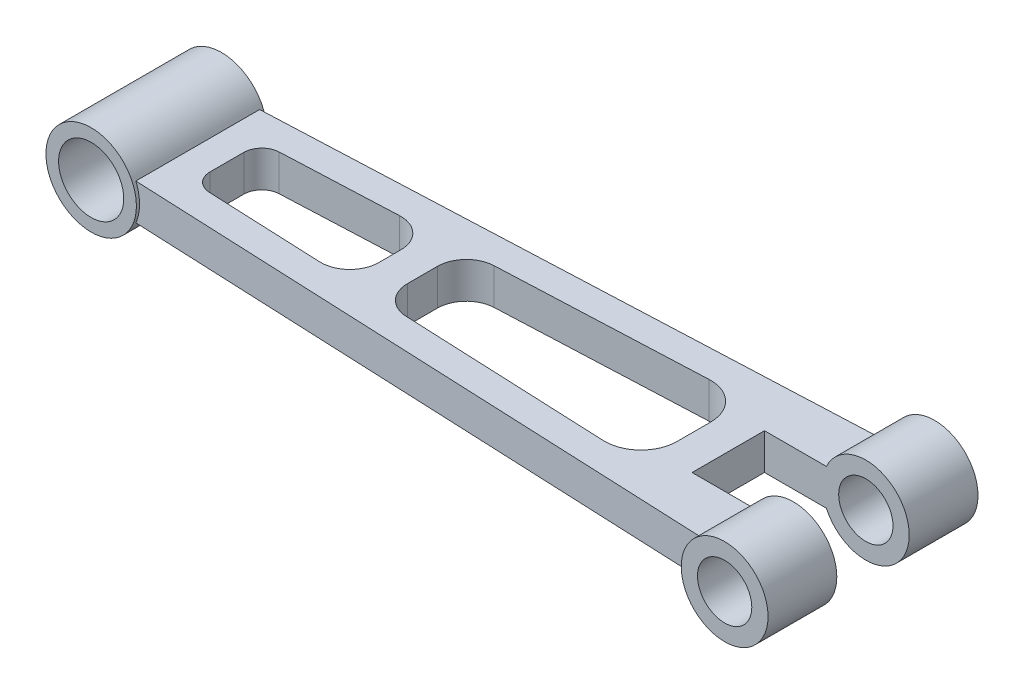
from build123d import *

# Parameters (mm, degrees)
BOSS_EXTRUDE1_DEPTH      = 10
SKETCH2_W                = 45.039354618
SKETCH2_H                = 20
CUT_EXTRUDE1_DEPTH       = 87.816421854
BOSS_EXTRUDE2_DEPTH      = 18
BOSS_EXTRUDE2_DEPTH_BACK = 18
SKETCH3_R                = 12.5
SKETCH4_R                = 9
CUT_EXTRUDE2_DEPTH       = 116.22555562
BOSS_EXTRUDE4_DEPTH      = 29
BOSS_EXTRUDE4_DEPTH_BACK = 29
SKETCH7_R                = 11.988578659
SKETCH8_R                = 7.5
CUT_EXTRUDE3_DEPTH       = 122.874166664
SKETCH2_2_W              = 45.039354618
SKETCH2_2_H              = 20
CUT_EXTRUDE4_DEPTH       = 112.041940275
CUT_EXTRUDE5_DEPTH       = 112.041940275
CUT_EXTRUDE5_DEPTH_BACK  = 112.041940275
SKETCH2_3_W              = 45.039354618
SKETCH2_3_H              = 20


with BuildPart() as part:
    # Sketch1 → Boss-Extrude1 (new body)
    with BuildSketch(Plane(origin=(0, 0, 0), x_dir=(1, 0, 0), z_dir=(0, 1, 0))):
        Polygon((-82.75, 0), (-82.75, 17.05432407), (82.75, 24.280210121), (82.75, 0), align=None)
    boss_extrude1 = extrude(amount=BOSS_EXTRUDE1_DEPTH)

    # Mirror1: Boss-Extrude1 across plane
    add(boss_extrude1.mirror(Plane.XY))

    # Sketch2 → Cut-Extrude1 (cut, through all)
    with BuildSketch(Plane(origin=(0, 10, 0), x_dir=(1, 0, 0), z_dir=(0, 1, 0))):
        with BuildLine():
            Line((-68.968096937, 9.648433472), (-37.098955099, 11.039870254))
            ThreePointArc((-37.098955099, 11.039870254), (-31.217895554, 8.826396178), (-28.75, 3.047484481))
            Line((-28.75, 3.047484481), (-28.75, -3.047484481))
            ThreePointArc((-28.75, -3.047484481), (-31.217895554, -8.826396178), (-37.098955099, -11.039870254))
            Line((-37.098955099, -11.039870254), (-68.968096937, -9.648433472))
            ThreePointArc((-68.968096937, -9.648433472), (-72.36181981, -8.110757643), (-73.75, -4.653192364))
            Line((-73.75, -4.653192364), (-73.75, 4.653192364))
            ThreePointArc((-73.75, 4.653192364), (-72.36181981, 8.110757643), (-68.968096937, 9.648433472))
        make_face()
        with BuildLine():
            Line((-19.75, 4.139008054), (-19.75, -4.139008054))
            ThreePointArc((-19.75, -4.139008054), (-17.528911696, -9.6711125), (-12.098955099, -12.131393827))
            Line((-12.098955099, -12.131393827), (44.813806126, -14.616258645))
            ThreePointArc((44.813806126, -14.616258645), (52.165130558, -11.84941605), (55.25, -4.625776429))
            Line((55.25, -4.625776429), (55.25, 4.625776429))
            ThreePointArc((55.25, 4.625776429), (52.165130558, 11.84941605), (44.813806126, 14.616258645))
            Line((44.813806126, 14.616258645), (-12.098955099, 12.131393827))
            ThreePointArc((-12.098955099, 12.131393827), (-17.528911696, 9.6711125), (-19.75, 4.139008054))
        make_face()
        with Locations((87.269677309, 0)):
            Rectangle(SKETCH2_W, SKETCH2_H)
    extrude(amount=-CUT_EXTRUDE1_DEPTH, mode=Mode.SUBTRACT)

    # Sketch7 → Boss-Extrude4 (add, two sides: drawn at the far end of the back side and taken through both)
    with BuildSketch(Plane.XY.offset(-BOSS_EXTRUDE4_DEPTH_BACK)):
        with Locations((92.740482216, 5)):
            Circle(SKETCH7_R)
    extrude(amount=BOSS_EXTRUDE4_DEPTH + BOSS_EXTRUDE4_DEPTH_BACK)

    # Sketch8 → Cut-Extrude3 (cut, through all)
    with BuildSketch(Plane.XY.offset(29)):
        with Locations((92.740482216, 5)):
            Circle(SKETCH8_R)
    extrude(amount=-CUT_EXTRUDE3_DEPTH, mode=Mode.SUBTRACT)

    # Sketch2_2 → Cut-Extrude4 (cut, through all)
    with BuildSketch(Plane(origin=(0, 10, 0), x_dir=(1, 0, 0), z_dir=(0, 1, 0))):
        with BuildLine():
            Line((-68.968096937, 9.648433472), (-37.098955099, 11.039870254))
            ThreePointArc((-37.098955099, 11.039870254), (-31.217895554, 8.826396178), (-28.75, 3.047484481))
            Line((-28.75, 3.047484481), (-28.75, -3.047484481))
            ThreePointArc((-28.75, -3.047484481), (-31.217895554, -8.826396178), (-37.098955099, -11.039870254))
            Line((-37.098955099, -11.039870254), (-68.968096937, -9.648433472))
            ThreePointArc((-68.968096937, -9.648433472), (-72.36181981, -8.110757643), (-73.75, -4.653192364))
            Line((-73.75, -4.653192364), (-73.75, 4.653192364))
            ThreePointArc((-73.75, 4.653192364), (-72.36181981, 8.110757643), (-68.968096937, 9.648433472))
        make_face()
        with BuildLine():
            Line((-19.75, 4.139008054), (-19.75, -4.139008054))
            ThreePointArc((-19.75, -4.139008054), (-17.528911696, -9.6711125), (-12.098955099, -12.131393827))
            Line((-12.098955099, -12.131393827), (44.813806126, -14.616258645))
            ThreePointArc((44.813806126, -14.616258645), (52.165130558, -11.84941605), (55.25, -4.625776429))
            Line((55.25, -4.625776429), (55.25, 4.625776429))
            ThreePointArc((55.25, 4.625776429), (52.165130558, 11.84941605), (44.813806126, 14.616258645))
            Line((44.813806126, 14.616258645), (-12.098955099, 12.131393827))
            ThreePointArc((-12.098955099, 12.131393827), (-17.528911696, 9.6711125), (-19.75, 4.139008054))
        make_face()
        with Locations((87.269677309, 0)):
            Rectangle(SKETCH2_2_W, SKETCH2_2_H)
    extrude(amount=-CUT_EXTRUDE4_DEPTH, mode=Mode.SUBTRACT)

    # Sketch2_3 → Cut-Extrude5 (cut, two sides: drawn at the far end of the back side and taken through both)
    with BuildSketch(Plane(origin=(0, 10, 0), x_dir=(1, 0, 0), z_dir=(0, 1, 0)).offset(-CUT_EXTRUDE5_DEPTH_BACK)):
        with BuildLine():
            Line((-68.968096937, 9.648433472), (-37.098955099, 11.039870254))
            ThreePointArc((-37.098955099, 11.039870254), (-31.217895554, 8.826396178), (-28.75, 3.047484481))
            Line((-28.75, 3.047484481), (-28.75, -3.047484481))
            ThreePointArc((-28.75, -3.047484481), (-31.217895554, -8.826396178), (-37.098955099, -11.039870254))
            Line((-37.098955099, -11.039870254), (-68.968096937, -9.648433472))
            ThreePointArc((-68.968096937, -9.648433472), (-72.36181981, -8.110757643), (-73.75, -4.653192364))
            Line((-73.75, -4.653192364), (-73.75, 4.653192364))
            ThreePointArc((-73.75, 4.653192364), (-72.36181981, 8.110757643), (-68.968096937, 9.648433472))
        make_face()
        with BuildLine():
            Line((-19.75, 4.139008054), (-19.75, -4.139008054))
            ThreePointArc((-19.75, -4.139008054), (-17.528911696, -9.6711125), (-12.098955099, -12.131393827))
            Line((-12.098955099, -12.131393827), (44.813806126, -14.616258645))
            ThreePointArc((44.813806126, -14.616258645), (52.165130558, -11.84941605), (55.25, -4.625776429))
            Line((55.25, -4.625776429), (55.25, 4.625776429))
            ThreePointArc((55.25, 4.625776429), (52.165130558, 11.84941605), (44.813806126, 14.616258645))
            Line((44.813806126, 14.616258645), (-12.098955099, 12.131393827))
            ThreePointArc((-12.098955099, 12.131393827), (-17.528911696, 9.6711125), (-19.75, 4.139008054))
        make_face()
        with Locations((87.269677309, 0)):
            Rectangle(SKETCH2_3_W, SKETCH2_3_H)
    extrude(amount=CUT_EXTRUDE5_DEPTH + CUT_EXTRUDE5_DEPTH_BACK, mode=Mode.SUBTRACT)


with BuildPart() as body_2:
    # Sketch3 → Boss-Extrude2 (new, two sides: drawn at the far end of the back side and taken through both)
    with BuildSketch(Plane.XY.offset(-BOSS_EXTRUDE2_DEPTH_BACK)):
        with Locations((-93.25, 5)):
            Circle(SKETCH3_R)
    extrude(amount=BOSS_EXTRUDE2_DEPTH + BOSS_EXTRUDE2_DEPTH_BACK)

    # Sketch4 → Cut-Extrude2 (cut, through all)
    with BuildSketch(Plane.XY.offset(18)):
        with Locations((-93.25, 5)):
            Circle(SKETCH4_R)
    extrude(amount=-CUT_EXTRUDE2_DEPTH, mode=Mode.SUBTRACT)


solid = Compound([part.part, body_2.part])
